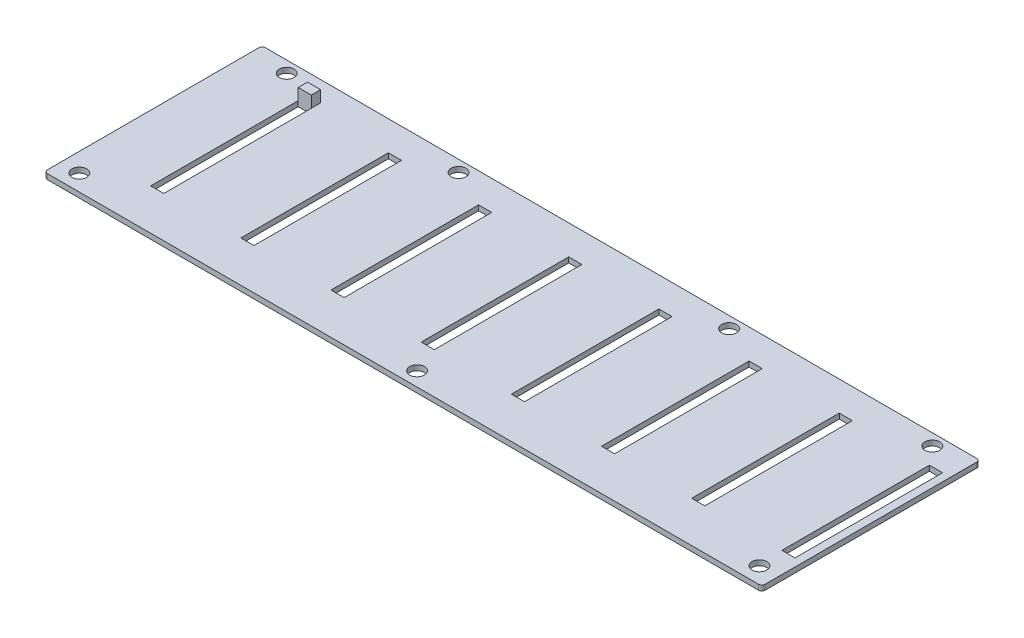
from build123d import *

# Parameters (mm, degrees)
SKETCH1_W           = 218.9
SKETCH1_H           = 66.5
SKETCH1_R           = 2.25
SKETCH1_W_2         = 4
SKETCH1_H_2         = 45
BOSS_EXTRUDE1_DEPTH = 1.6
FILLET1_R           = 1
SKETCH3_W           = 4
SKETCH3_H           = 2.831639971
BOSS_EXTRUDE2_DEPTH = 5.1


with BuildPart() as part:
    # Sketch1 → Boss-Extrude1 (new body)
    with BuildSketch(Plane(origin=(0, 0, 0), x_dir=(1, 0, 0), z_dir=(0, 1, 0))):
        with Locations((109.45, 33.25)):
            Rectangle(SKETCH1_W, SKETCH1_H)
        with Locations((11, 63)):
            Circle(SKETCH1_R, mode=Mode.SUBTRACT)
        with Locations((63.4, 63)):
            Circle(SKETCH1_R, mode=Mode.SUBTRACT)
        with Locations((145.9, 63)):
            Circle(SKETCH1_R, mode=Mode.SUBTRACT)
        with Locations((207.9, 63)):
            Circle(SKETCH1_R, mode=Mode.SUBTRACT)
        with Locations((5.75, 5)):
            Circle(SKETCH1_R, mode=Mode.SUBTRACT)
        with Locations((109.45, 4.3)):
            Circle(SKETCH1_R, mode=Mode.SUBTRACT)
        with Locations((213.15, 5)):
            Circle(SKETCH1_R, mode=Mode.SUBTRACT)
        with Locations((22, 35)):
            Rectangle(SKETCH1_W_2, SKETCH1_H_2, mode=Mode.SUBTRACT)
        with Locations((49.5, 35)):
            Rectangle(SKETCH1_W_2, SKETCH1_H_2, mode=Mode.SUBTRACT)
        with Locations((77, 35)):
            Rectangle(SKETCH1_W_2, SKETCH1_H_2, mode=Mode.SUBTRACT)
        with Locations((104.5, 35)):
            Rectangle(SKETCH1_W_2, SKETCH1_H_2, mode=Mode.SUBTRACT)
        with Locations((132, 35)):
            Rectangle(SKETCH1_W_2, SKETCH1_H_2, mode=Mode.SUBTRACT)
        with Locations((159.5, 35)):
            Rectangle(SKETCH1_W_2, SKETCH1_H_2, mode=Mode.SUBTRACT)
        with Locations((187, 35)):
            Rectangle(SKETCH1_W_2, SKETCH1_H_2, mode=Mode.SUBTRACT)
        with Locations((214.5, 35)):
            Rectangle(SKETCH1_W_2, SKETCH1_H_2, mode=Mode.SUBTRACT)
    extrude(amount=BOSS_EXTRUDE1_DEPTH)

    # Fillet1
    fillet1_edges = [part.edges().sort_by_distance(p)[0] for p in [
        (0, 0.8, -66.5),
        (218.9, 0.8, -66.5),
        (218.9, 0.8, 0),
        (0, 0.8, 0),
    ]]
    fillet(fillet1_edges, radius=FILLET1_R)

    # Sketch3 → Boss-Extrude2 (add)
    with BuildSketch(Plane(origin=(0, 0, 0), x_dir=(1, 0, 0), z_dir=(0, 1, 0))):
        with Locations((22, 58.915819986)):
            Rectangle(SKETCH3_W, SKETCH3_H)
    extrude(amount=BOSS_EXTRUDE2_DEPTH)


solid = part.part
